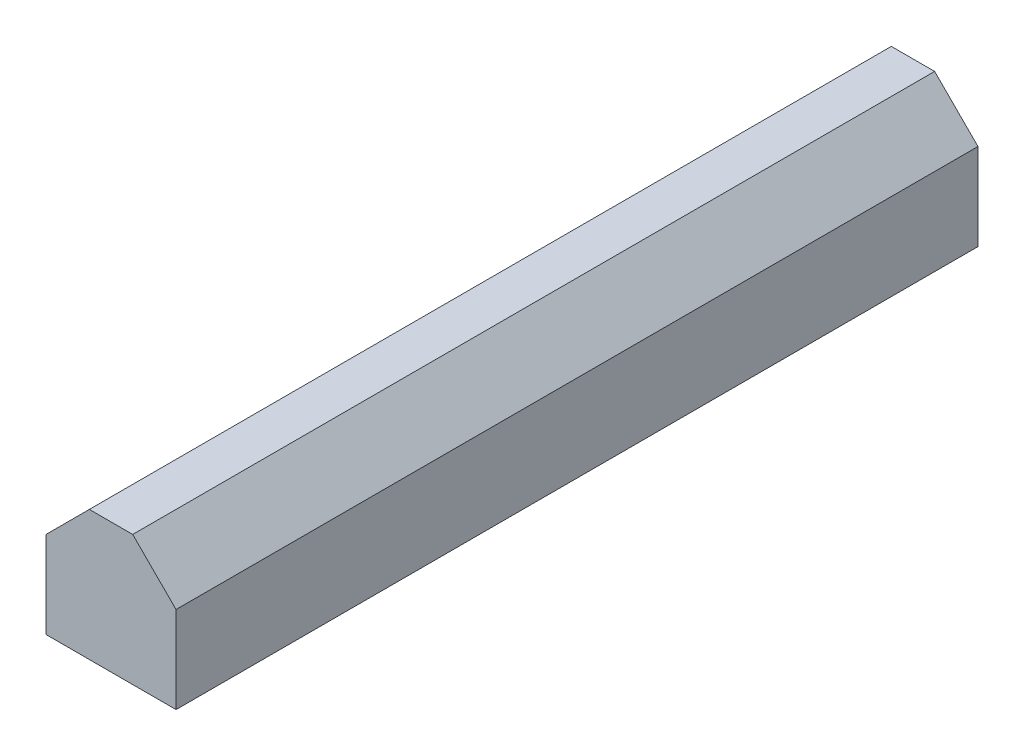
from build123d import *

# Parameters (mm, degrees)
EXTRUDE_1_DEPTH = 37


with BuildPart() as part:
    # Эскиз1 → Бобышка-Вытянуть1 (new body)
    with BuildSketch(Plane.XY):
        Polygon((3, 4.5), (-3, 4.5), (-3, 8.5), (-1, 10.5), (1, 10.5), (3, 8.5), align=None)
    extrude(amount=-EXTRUDE_1_DEPTH)


solid = part.part
